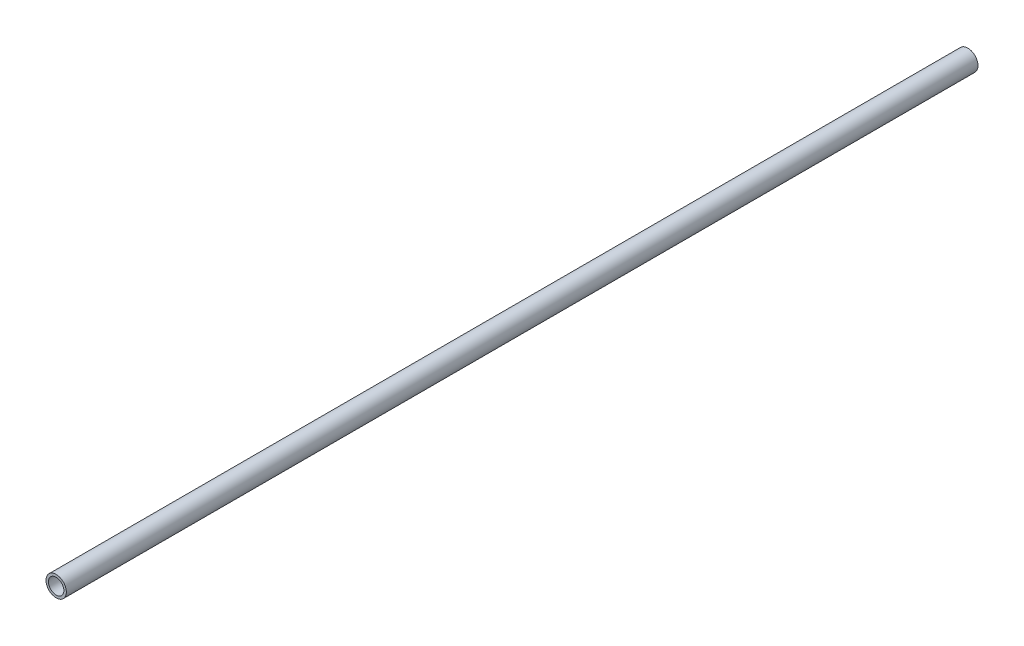
from build123d import *

# Parameters (mm, degrees)
CROQUIS1_R              = 16.75
SALIENTE_EXTRUIR1_DEPTH = 1500
CROQUIS2_R              = 12.7
CORTAR_EXTRUIR1_DEPTH   = 1500


with BuildPart() as part:
    # Croquis1 → Saliente-Extruir1 (new body)
    with BuildSketch(Plane.XY):
        Circle(CROQUIS1_R)
    extrude(amount=SALIENTE_EXTRUIR1_DEPTH)

    # Croquis2 → Cortar-Extruir1 (cut)
    with BuildSketch(Plane.XY.offset(1500)):
        Circle(CROQUIS2_R)
    extrude(amount=-CORTAR_EXTRUIR1_DEPTH, mode=Mode.SUBTRACT)


solid = part.part
